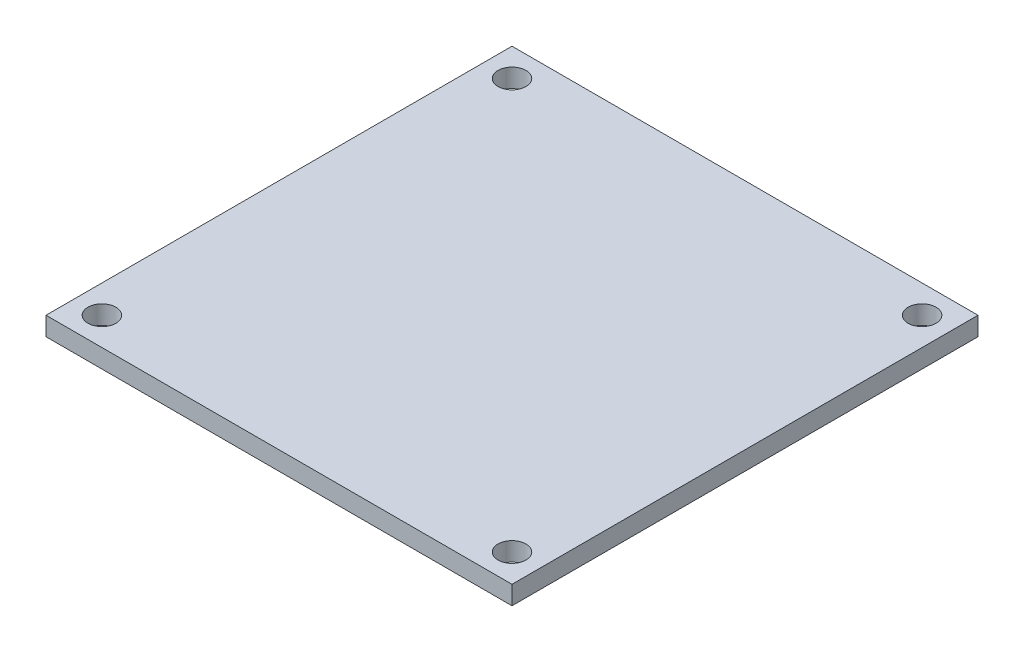
from build123d import *

# Parameters (mm, degrees)
CROQUIS1_W              = 50
CROQUIS1_H              = 50
CROQUIS1_R              = 1.5
SALIENTE_EXTRUIR4_DEPTH = 2


with BuildPart() as part:
    # Croquis1 → Saliente-Extruir4 (new body)
    with BuildSketch(Plane(origin=(0, 0, 0), x_dir=(1, 0, 0), z_dir=(0, 1, 0))):
        with Locations((-35, 0)):
            Rectangle(CROQUIS1_W, CROQUIS1_H)
        with Locations((-57, -22)):
            Circle(CROQUIS1_R, mode=Mode.SUBTRACT)
        with Locations((-13, -22)):
            Circle(CROQUIS1_R, mode=Mode.SUBTRACT)
        with Locations((-13, 22)):
            Circle(CROQUIS1_R, mode=Mode.SUBTRACT)
        with Locations((-57, 22)):
            Circle(CROQUIS1_R, mode=Mode.SUBTRACT)
    extrude(amount=SALIENTE_EXTRUIR4_DEPTH)


solid = part.part
